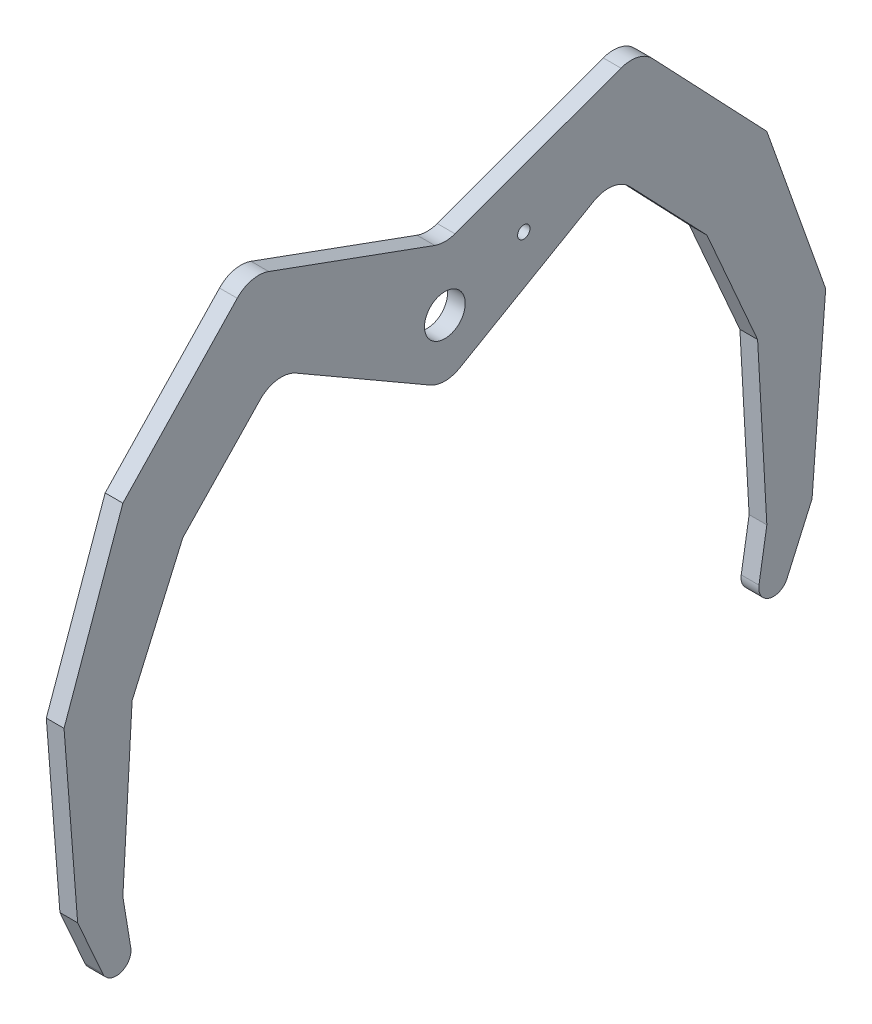
from build123d import *

# Parameters (mm, degrees)
SKETCH1_R           = 3.45
SKETCH1_R_2         = 1.05
BOSS_EXTRUDE1_DEPTH = 3


with BuildPart() as part:
    # Sketch1 → Boss-Extrude1 (new body)
    with BuildSketch(Plane(origin=(0, 0, 0), x_dir=(0, 0, -1), z_dir=(1, 0, 0))):
        with BuildLine():
            Line((1.710100717, 11.072425758), (29.81221294, 21.300758128))
            ThreePointArc((29.81221294, 21.300758128), (32.665838041, 21.469774041), (35.145679665, 20.04775853))
            Line((35.145679665, 20.04775853), (54.503522355, -0.309603856))
            Line((54.503522355, -0.309603856), (64.462541824, -28.342275903))
            Line((64.462541824, -28.342275903), (62.158643896, -58.002094263))
            Line((62.158643896, -58.002094263), (57.918218143, -67.574774191))
            ThreePointArc((57.918218143, -67.574774191), (54.918016136, -68.957985447), (53.165427908, -66.157464075))
            Line((53.165427908, -66.157464075), (54.503522355, -58.002094263))
            Line((54.503522355, -58.002094263), (52.939962821, -30.04554677))
            Line((52.939962821, -30.04554677), (44.360806264, -10.45))
            Line((44.360806264, -10.45), (31.292334945, 3.213047447))
            ThreePointArc((31.292334945, 3.213047447), (28.386766522, 4.706668614), (25.179055571, 4.087134512))
            Line((25.179055571, 4.087134512), (2.5, -9.006624327))
            ThreePointArc((2.5, -9.006624327), (0, -9.676497308), (-2.5, -9.006624327))
            Line((-2.5, -9.006624327), (-25.179055571, 4.087134512))
            ThreePointArc((-25.179055571, 4.087134512), (-28.386766522, 4.706668614), (-31.292334945, 3.213047447))
            Line((-31.292334945, 3.213047447), (-44.360806264, -10.45))
            Line((-44.360806264, -10.45), (-52.939962821, -30.04554677))
            Line((-52.939962821, -30.04554677), (-54.503522355, -58.002094263))
            Line((-54.503522355, -58.002094263), (-53.165427908, -66.157464075))
            ThreePointArc((-53.165427908, -66.157464075), (-54.918016136, -68.957985447), (-57.918218143, -67.574774191))
            Line((-57.918218143, -67.574774191), (-62.158643896, -58.002094263))
            Line((-62.158643896, -58.002094263), (-64.462541824, -28.342275903))
            Line((-64.462541824, -28.342275903), (-54.503522355, -0.309603856))
            Line((-54.503522355, -0.309603856), (-35.145679665, 20.04775853))
            ThreePointArc((-35.145679665, 20.04775853), (-32.665838041, 21.469774041), (-29.81221294, 21.300758128))
            Line((-29.81221294, 21.300758128), (-1.710100717, 11.072425758))
            ThreePointArc((-1.710100717, 11.072425758), (0, 10.770888862), (1.710100717, 11.072425758))
        make_face()
        Circle(SKETCH1_R, mode=Mode.SUBTRACT)
        with Locations((13.357740048, 5.51119595)):
            Circle(SKETCH1_R_2, mode=Mode.SUBTRACT)
    extrude(amount=BOSS_EXTRUDE1_DEPTH)


solid = part.part
